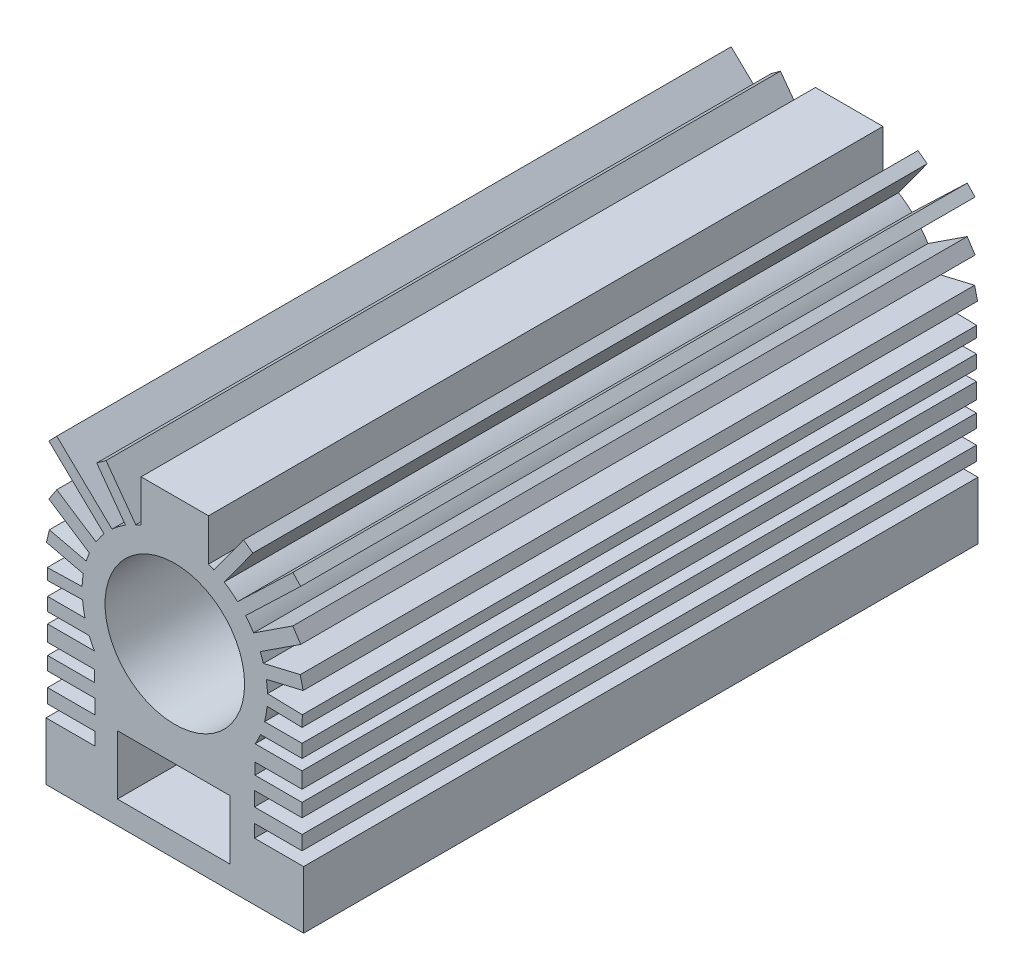
from build123d import *

# Parameters (mm, degrees)
SKETCH1_R           = 6
SKETCH1_W           = 9.664317132
SKETCH1_H           = 5.093827802
BOSS_EXTRUDE1_DEPTH = 58
SKETCH2_R           = 2.5
SKETCH2_R_2         = 1.557642262
CUT_EXTRUDE1_DEPTH  = 10


with BuildPart() as part:
    # Sketch1 → Boss-Extrude1 (new body)
    with BuildSketch(Plane.XY):
        with BuildLine():
            Line((-9.822104082, -25.661413332), (-5.082925118, -30.205025059))
            ThreePointArc((-5.082925118, -30.205025059), (-5.444381805, -30.665269108), (-5.771113852, -31.15078089))
            Line((-5.771113852, -31.15078089), (-9.145384533, -28.943772104))
            Line((-9.145384533, -28.943772104), (-9.823578986, -29.980655904))
            Line((-9.823578986, -29.980655904), (-6.344193142, -32.256417352))
            ThreePointArc((-6.344193142, -32.256417352), (-6.488837019, -32.624364602), (-6.615069482, -32.999027645))
            Line((-6.615069482, -32.999027645), (-9.783580045, -32.250497314))
            Line((-9.783580045, -32.250497314), (-10.034391467, -33.312175922))
            Line((-10.034391467, -33.312175922), (-6.865985046, -34.060689065))
            ThreePointArc((-6.865985046, -34.060689065), (-6.932730681, -34.565893765), (-6.967078624, -35.074329589))
            Line((-6.967078624, -35.074329589), (-9.963607891, -35.148687431))
            Line((-9.963607891, -35.148687431), (-9.93976563, -36.109501168))
            Line((-9.93976563, -36.109501168), (-6.926935836, -36.033753282))
            ThreePointArc((-6.926935836, -36.033753282), (-6.847527662, -36.665356301), (-6.717901152, -37.288593816))
            Line((-6.717901152, -37.288593816), (-9.93976563, -37.288593816))
            Line((-9.93976563, -37.288593816), (-9.93976563, -38.42012165))
            Line((-9.93976563, -38.42012165), (-6.362008263, -38.42012165))
            ThreePointArc((-6.362008263, -38.42012165), (-6.149413668, -38.888266643), (-5.907103174, -39.341744119))
            Line((-5.907103174, -39.341744119), (-9.93976563, -39.341744119))
            Line((-9.93976563, -39.341744119), (-9.93976563, -40.709698074))
            Line((-9.93976563, -40.709698074), (-5.907103174, -40.709698074))
            Line((-5.907103174, -40.709698074), (-5.889625491, -41.688448301))
            Line((-5.889625491, -41.688448301), (-9.93976563, -41.688448301))
            Line((-9.93976563, -41.688448301), (-9.93976563, -42.842115912))
            Line((-9.93976563, -42.842115912), (-5.847543839, -42.842115912))
            Line((-5.847543839, -42.842115912), (-5.847543839, -44.079099033))
            Line((-5.847543839, -44.079099033), (-9.93976563, -44.079099033))
            Line((-9.93976563, -44.079099033), (-9.93976563, -45.299533915))
            Line((-9.93976563, -45.299533915), (-5.847543839, -45.299533915))
            Line((-5.847543839, -45.299533915), (-5.847543839, -46.402625605))
            Line((-5.847543839, -46.402625605), (-10.073482588, -46.402625605))
            Line((-10.073482588, -46.402625605), (-10.073482588, -51.367819628))
            Line((-10.073482588, -51.367819628), (-5.904369685, -51.367819628))
            Line((-5.904369685, -51.367819628), (1.003920553, -51.367819628))
            Line((1.003920553, -51.367819628), (7.912210791, -51.367819628))
            Line((7.912210791, -51.367819628), (12.081323694, -51.367819628))
            Line((12.081323694, -51.367819628), (12.081323694, -46.402625605))
            Line((12.081323694, -46.402625605), (7.855384945, -46.402625605))
            Line((7.855384945, -46.402625605), (7.855384945, -45.299533915))
            Line((7.855384945, -45.299533915), (11.947606735, -45.299533915))
            Line((11.947606735, -45.299533915), (11.947606735, -44.079099033))
            Line((11.947606735, -44.079099033), (7.855384945, -44.079099033))
            Line((7.855384945, -44.079099033), (7.855384945, -42.842115912))
            Line((7.855384945, -42.842115912), (11.947606735, -42.842115912))
            Line((11.947606735, -42.842115912), (11.947606735, -41.688448301))
            Line((11.947606735, -41.688448301), (7.897466597, -41.688448301))
            Line((7.897466597, -41.688448301), (7.914944279, -40.709698074))
            Line((7.914944279, -40.709698074), (11.947606735, -40.709698074))
            Line((11.947606735, -40.709698074), (11.947606735, -39.341744119))
            Line((11.947606735, -39.341744119), (7.914944279, -39.341744119))
            ThreePointArc((7.914944279, -39.341744119), (8.157254773, -38.888266643), (8.369849369, -38.42012165))
            Line((8.369849369, -38.42012165), (11.947606735, -38.42012165))
            Line((11.947606735, -38.42012165), (11.947606735, -37.288593816))
            Line((11.947606735, -37.288593816), (8.725742258, -37.288593816))
            ThreePointArc((8.725742258, -37.288593816), (8.855368768, -36.665356301), (8.934776942, -36.033753282))
            Line((8.934776942, -36.033753282), (11.947606735, -36.109501168))
            Line((11.947606735, -36.109501168), (11.971448997, -35.148687431))
            Line((11.971448997, -35.148687431), (8.974919729, -35.074329589))
            ThreePointArc((8.974919729, -35.074329589), (8.940571786, -34.565893765), (8.873826152, -34.060689065))
            Line((8.873826152, -34.060689065), (12.042232573, -33.312175922))
            Line((12.042232573, -33.312175922), (11.791421151, -32.250497314))
            Line((11.791421151, -32.250497314), (8.622910588, -32.999027645))
            ThreePointArc((8.622910588, -32.999027645), (8.496678124, -32.624364602), (8.352034248, -32.256417352))
            Line((8.352034248, -32.256417352), (11.831420091, -29.980655904))
            Line((11.831420091, -29.980655904), (11.153225638, -28.943772104))
            Line((11.153225638, -28.943772104), (7.778954958, -31.15078089))
            ThreePointArc((7.778954958, -31.15078089), (7.452222911, -30.665269108), (7.090766224, -30.205025059))
            Line((7.090766224, -30.205025059), (11.829945188, -25.661413332))
            Line((11.829945188, -25.661413332), (11.155479277, -24.957916896))
            Line((11.155479277, -24.957916896), (6.404976787, -29.512384871))
            ThreePointArc((6.404976787, -29.512384871), (5.847311339, -29.042565295), (5.248984501, -28.625760566))
            Line((5.248984501, -28.625760566), (7.716155949, -25.236928133))
            Line((7.716155949, -25.236928133), (6.917652539, -24.655593749))
            Line((6.917652539, -24.655593749), (4.363311136, -28.164160209))
            ThreePointArc((4.363311136, -28.164160209), (4.135366319, -28.062042381), (3.904321948, -27.967145652))
            Line((3.904321948, -27.967145652), (3.904321948, -24.362789588))
            Line((3.904321948, -24.362789588), (-1.896480842, -24.362789588))
            Line((-1.896480842, -24.362789588), (-1.896480842, -27.967145652))
            ThreePointArc((-1.896480842, -27.967145652), (-2.127525214, -28.062042381), (-2.35547003, -28.164160209))
            Line((-2.35547003, -28.164160209), (-4.909811434, -24.655593749))
            Line((-4.909811434, -24.655593749), (-5.708314844, -25.236928133))
            Line((-5.708314844, -25.236928133), (-3.241143396, -28.625760566))
            ThreePointArc((-3.241143396, -28.625760566), (-3.839470233, -29.042565295), (-4.397135681, -29.512384871))
            Line((-4.397135681, -29.512384871), (-9.147638171, -24.957916896))
            Line((-9.147638171, -24.957916896), (-9.822104082, -25.661413332))
        make_face()
        with Locations((1.003920553, -35.357441113)):
            Circle(SKETCH1_R, mode=Mode.SUBTRACT)
        with Locations((0.899494134, -46.834148598)):
            Rectangle(SKETCH1_W, SKETCH1_H, mode=Mode.SUBTRACT)
    extrude(amount=BOSS_EXTRUDE1_DEPTH)

    # Sketch2 → Cut-Extrude1 (cut)
    with BuildSketch(Plane.XZ.offset(51.367819628)):
        with Locations((1.188364706, 29)):
            Circle(SKETCH2_R)
        with Locations((-6.573482588, 10)):
            Circle(SKETCH2_R_2)
        with Locations((9.191259736, 10.100266019)):
            Circle(SKETCH2_R_2)
        with Locations((9.191259736, 47.899733981)):
            Circle(SKETCH2_R_2)
        with Locations((-6.573482588, 48)):
            Circle(SKETCH2_R_2)
    extrude(amount=-CUT_EXTRUDE1_DEPTH, mode=Mode.SUBTRACT)


solid = part.part
